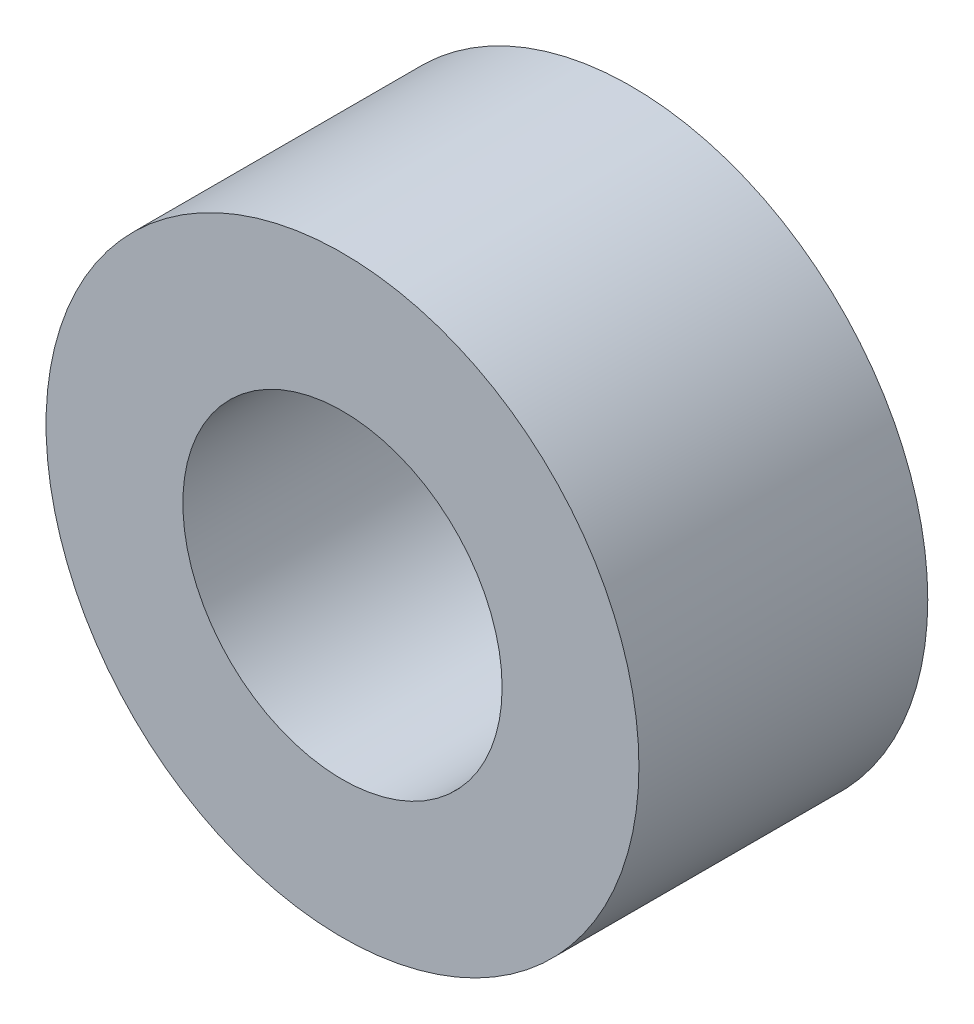
from build123d import *

# Parameters (mm, degrees)
SKETCH1_R           = 19.5
SKETCH1_R_2         = 10.5
BOSS_EXTRUDE1_DEPTH = 19


with BuildPart() as part:
    # Sketch1 → Boss-Extrude1 (new body)
    with BuildSketch(Plane.XY):
        Circle(SKETCH1_R)
        Circle(SKETCH1_R_2, mode=Mode.SUBTRACT)
    extrude(amount=BOSS_EXTRUDE1_DEPTH)


solid = part.part
